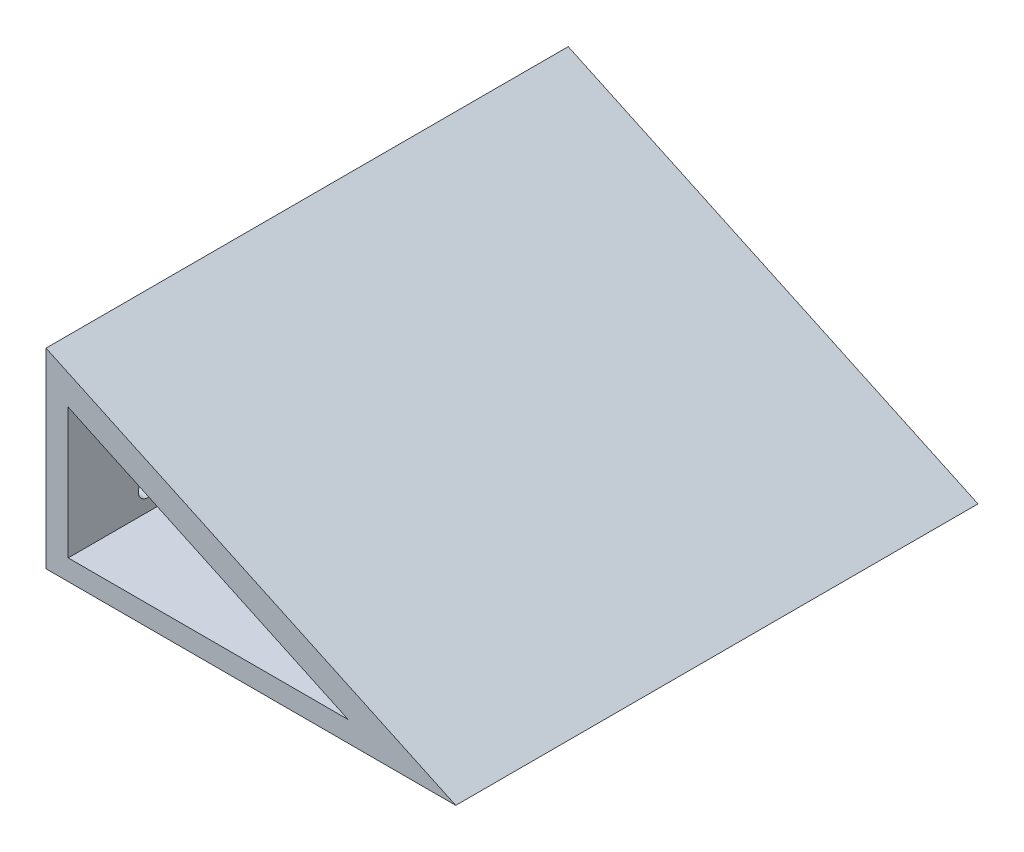
from build123d import *

# Parameters (mm, degrees)
SKETCH2_W           = 257.3
SKETCH2_H           = 327.9
BOSS_EXTRUDE1_DEPTH = 120
CUT_EXTRUDE1_DEPTH  = 330
CUT_EXTRUDE2_DEPTH  = 425
SKETCH5_R           = 6
CUT_EXTRUDE3_DEPTH  = 21


with BuildPart() as part:
    # Sketch2 → Boss-Extrude1 (new body)
    with BuildSketch(Plane(origin=(0, 0, 0), x_dir=(1, 0, 0), z_dir=(0, 1, 0))):
        Rectangle(SKETCH2_W, SKETCH2_H)
    extrude(amount=BOSS_EXTRUDE1_DEPTH)

    # Sketch3 → Cut-Extrude1 (cut)
    with BuildSketch(Plane.XY.offset(163.95)):
        Polygon((128.65, 0), (-128.65, 120), (128.65, 120), align=None)
    extrude(amount=-CUT_EXTRUDE1_DEPTH, mode=Mode.SUBTRACT)

    # Sketch4 → Cut-Extrude2 (cut)
    with BuildSketch(Plane.XY.offset(163.95)):
        Polygon((-114.703132504, 94.894537232), (-114.703132504, 12.894537232), (61.096867496, 12.894537232), align=None)
    extrude(amount=-CUT_EXTRUDE2_DEPTH, mode=Mode.SUBTRACT)

    # Sketch5 → Cut-Extrude3 (cut)
    with BuildSketch(Plane.ZY.offset(128.65)):
        with Locations((-114.05, 80)):
            Circle(SKETCH5_R)
        with Locations((-114.05, 26.7)):
            Circle(SKETCH5_R)
        with Locations((113.95, 80)):
            Circle(SKETCH5_R)
        with Locations((113.95, 26.7)):
            Circle(SKETCH5_R)
    extrude(amount=-CUT_EXTRUDE3_DEPTH, mode=Mode.SUBTRACT)


solid = part.part
